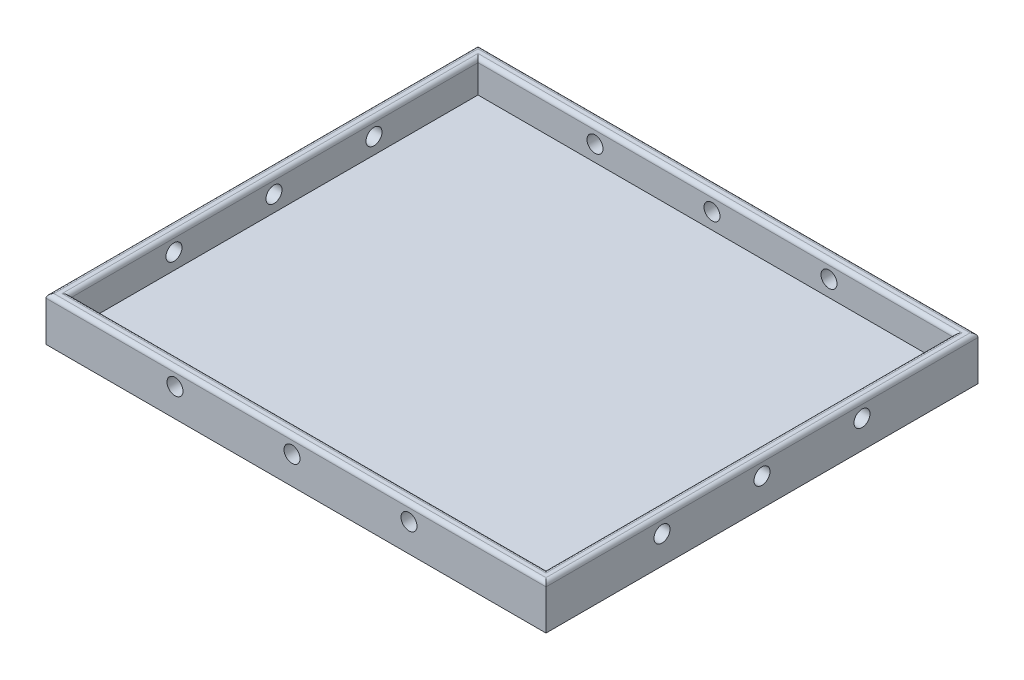
from build123d import *

# Parameters (mm, degrees)
SKETCH1_W               = 125
SKETCH1_H               = 108
BOSS_EXTRUDE1_DEPTH     = 11
SKETCH4_W               = 119
SKETCH4_H               = 102
CUT_EXTRUDE1_DEPTH      = 8
SKETCH6_R               = 2
CUT_EXTRUDE6_DEPTH      = 123
CUT_EXTRUDE6_DEPTH_BACK = 4
SKETCH5_R               = 2
CUT_EXTRUDE5_DEPTH      = 106
CUT_EXTRUDE5_DEPTH_BACK = 4
FILLET2_R               = 1


with BuildPart() as part:
    # Sketch1 → Boss-Extrude1 (new body)
    with BuildSketch(Plane(origin=(0, 0, 0), x_dir=(1, 0, 0), z_dir=(0, 1, 0))):
        with Locations((-139.109907121, 23.894736842)):
            Rectangle(SKETCH1_W, SKETCH1_H)
    extrude(amount=BOSS_EXTRUDE1_DEPTH)

    # Sketch4 → Cut-Extrude1 (cut)
    with BuildSketch(Plane(origin=(0, 11, 0), x_dir=(1, 0, 0), z_dir=(0, 1, 0))):
        with Locations((-139.109907121, 23.894736842)):
            Rectangle(SKETCH4_W, SKETCH4_H)
    extrude(amount=-CUT_EXTRUDE1_DEPTH, mode=Mode.SUBTRACT)

    # Sketch6 → Cut-Extrude6 (cut, two sides)
    with BuildSketch(Plane(origin=(-198.609907121, 0, 0), x_dir=(0, 0, -1), z_dir=(1, 0, 0))) as cut_extrude6_sk:
        with Locations((-1.105263158, 6.999999953)):
            Circle(SKETCH6_R)
        with Locations((23.894736842, 6.999999977)):
            Circle(SKETCH6_R)
        with Locations((48.894736842, 7)):
            Circle(SKETCH6_R)
    extrude(amount=CUT_EXTRUDE6_DEPTH, mode=Mode.SUBTRACT)
    extrude(cut_extrude6_sk.sketch, amount=-CUT_EXTRUDE6_DEPTH_BACK, mode=Mode.SUBTRACT)

    # Sketch5 → Cut-Extrude5 (cut, two sides)
    with BuildSketch(Plane.XY.offset(-74.894736842)) as cut_extrude5_sk:
        with Locations((-169.359907121, 7)):
            Circle(SKETCH5_R)
        with Locations((-140.109907121, 7)):
            Circle(SKETCH5_R)
        with Locations((-110.859907121, 7)):
            Circle(SKETCH5_R)
    extrude(amount=CUT_EXTRUDE5_DEPTH, mode=Mode.SUBTRACT)
    extrude(cut_extrude5_sk.sketch, amount=-CUT_EXTRUDE5_DEPTH_BACK, mode=Mode.SUBTRACT)

    # Fillet2
    fillet2_edges = [part.edges().sort_by_distance(p)[0] for p in [
        (-76.609907121, 11, -23.894736842),
        (-139.109907121, 11, -77.894736842),
        (-198.609907121, 11, -23.894736842),
        (-139.109907121, 11, 27.105263158),
        (-79.609907121, 11, -23.894736842),
        (-139.109907121, 11, -74.894736842),
        (-201.609907121, 11, -23.894736842),
        (-139.109907121, 11, 30.105263158),
    ]]
    fillet(fillet2_edges, radius=FILLET2_R)


solid = part.part
